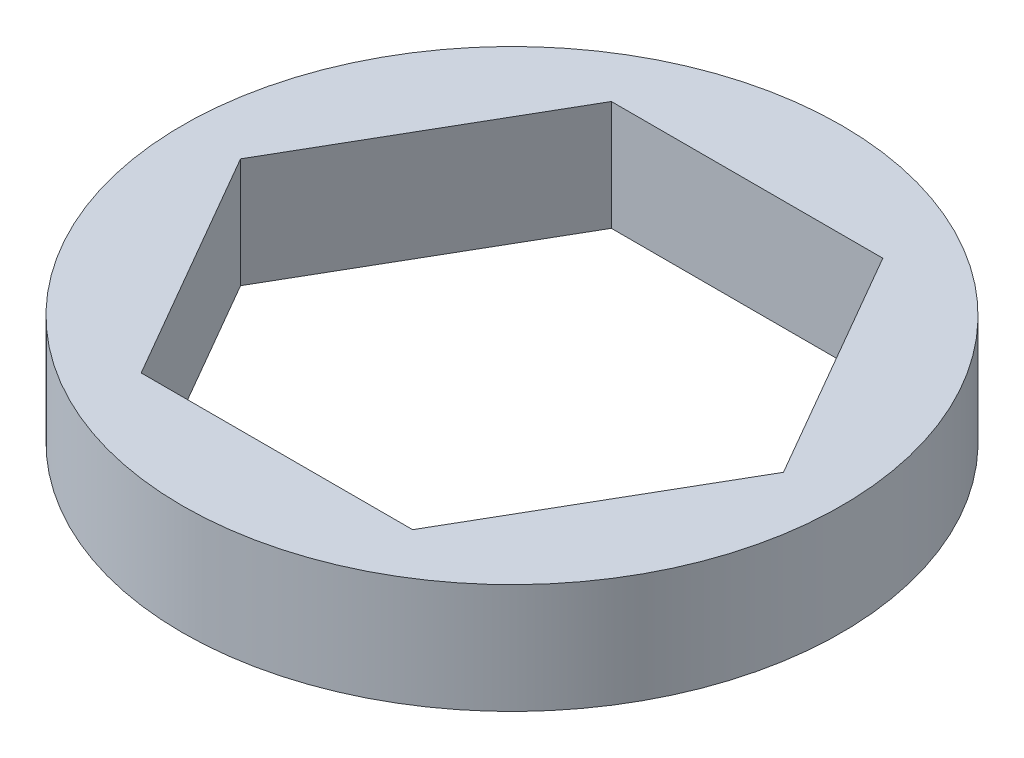
from build123d import *

# Parameters (mm, degrees)
SKETCH1_R           = 9.525
BOSS_EXTRUDE1_DEPTH = 3.175


with BuildPart() as part:
    # Sketch1 → Boss-Extrude1 (new body)
    with BuildSketch(Plane(origin=(0, 0, 0), x_dir=(1, 0, 0), z_dir=(0, 1, 0))):
        Circle(SKETCH1_R)
        Polygon((3.922806404, -6.7945), (7.845612808, 0), (3.922806404, 6.7945), (-3.922806404, 6.7945), (-7.845612808, 0), (-3.922806404, -6.7945), align=None, mode=Mode.SUBTRACT)
    extrude(amount=BOSS_EXTRUDE1_DEPTH)


solid = part.part
